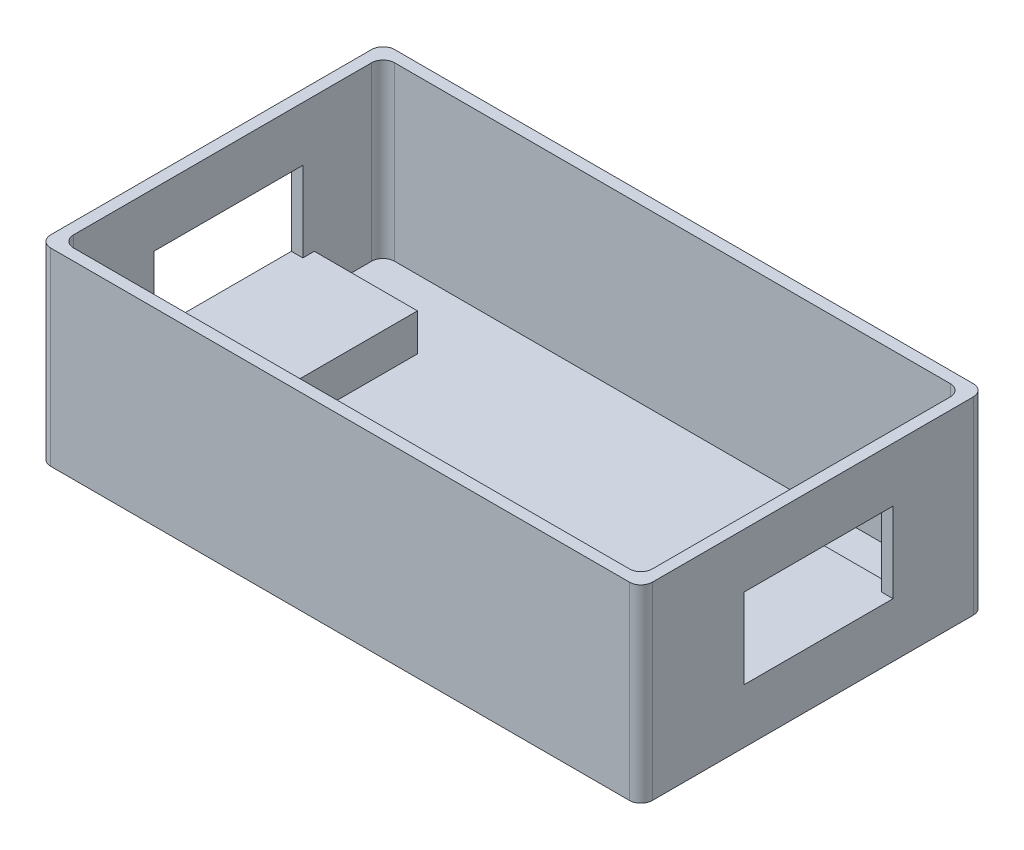
from build123d import *

# Parameters (mm, degrees)
BOSS_EXTRU_1_DEPTH      = 3
ESQUISSE3_W             = 105
ESQUISSE3_H             = 60
ESQUISSE3_W_2           = 101
ESQUISSE3_H_2           = 56
BOSS_EXTRU_2_DEPTH      = 30
CONG_2_R                = 2
CONG_4_R                = 2
ESQUISSE4_W             = 26
ESQUISSE4_H             = 14
ENL_V_MAT_EXTRU_2_DEPTH = 162
ESQUISSE6_W             = 18
ESQUISSE6_H             = 30
BOSS_EXTRU_7_DEPTH      = 6.5


with BuildPart() as part:
    # Esquisse2 → Boss.-Extru.1 (new body)
    with BuildSketch(Plane(origin=(0, 0, 0), x_dir=(1, 0, 0), z_dir=(0, 1, 0))):
        Polygon((0, 30), (-52.5, 30), (-52.5, -30), (0, -30), (52.5, -30), (52.5, 30), align=None)
    extrude(amount=BOSS_EXTRU_1_DEPTH)

    # Esquisse3 → Boss.-Extru.2 (add)
    with BuildSketch(Plane(origin=(0, 3, 0), x_dir=(1, 0, 0), z_dir=(0, 1, 0))):
        Rectangle(ESQUISSE3_W, ESQUISSE3_H)
        Rectangle(ESQUISSE3_W_2, ESQUISSE3_H_2, mode=Mode.SUBTRACT)
    extrude(amount=BOSS_EXTRU_2_DEPTH)

    # Congé2
    cong_2_edges = [part.edges().sort_by_distance(p)[0] for p in [
        (52.5, 16.5, -30),
        (52.5, 16.5, 30),
        (-52.5, 16.5, 30),
        (-52.5, 16.5, -30),
    ]]
    fillet(cong_2_edges, radius=CONG_2_R)

    # Congé4
    cong_4_edges = [part.edges().sort_by_distance(p)[0] for p in [
        (-50.5, 18, 28),
        (50.5, 18, 28),
        (50.5, 18, -28),
        (-50.5, 18, -28),
    ]]
    fillet(cong_4_edges, radius=CONG_4_R)

    # Esquisse4 → Enlèv. mat.-Extru.2 (cut)
    with BuildSketch(Plane.ZY.offset(52.5)):
        with Locations((-1, 16.5)):
            Rectangle(ESQUISSE4_W, ESQUISSE4_H)
    extrude(amount=-ENL_V_MAT_EXTRU_2_DEPTH, mode=Mode.SUBTRACT)

    # Esquisse6 → Boss.-Extru.7 (add)
    with BuildSketch(Plane(origin=(0, 3, 0), x_dir=(1, 0, 0), z_dir=(0, 1, 0))):
        with Locations((-41.5, 1)):
            Rectangle(ESQUISSE6_W, ESQUISSE6_H)
    boss_extru_7 = extrude(amount=BOSS_EXTRU_7_DEPTH)

    # Symétrie1: Boss.-Extru.7 across plane
    add(boss_extru_7.mirror(Plane(origin=(0, 0, 0), x_dir=(0, 0, 1), z_dir=(1, 0, 0))))


solid = part.part
